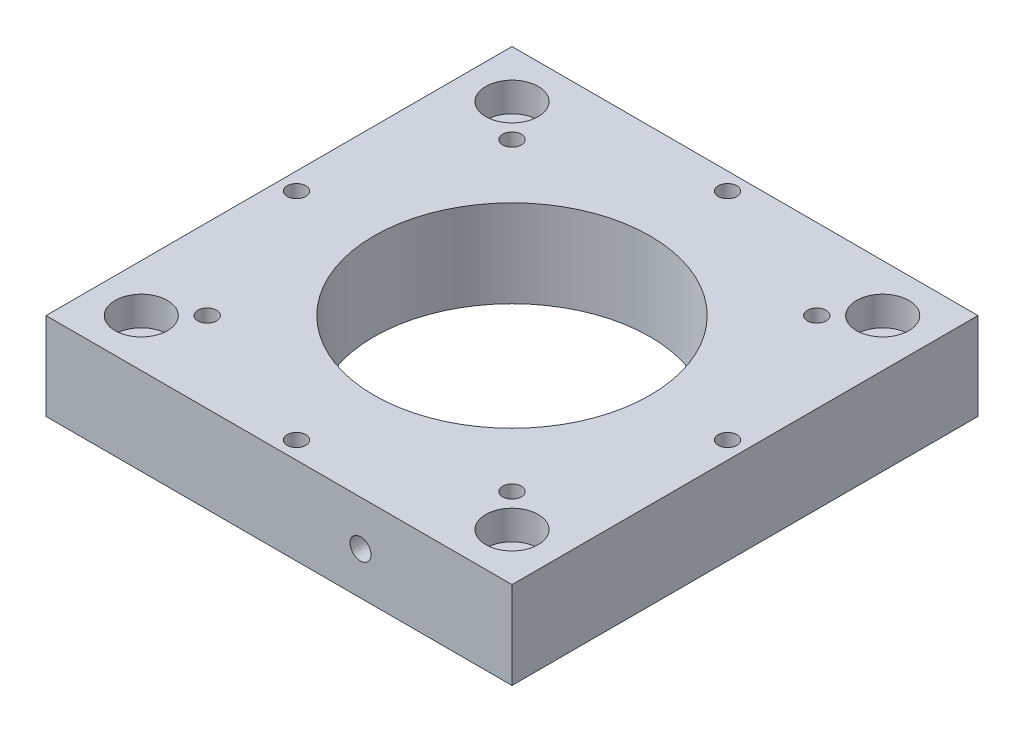
from build123d import *

# Parameters (mm, degrees)
SKETCH_22_W         = 80
SKETCH_22_H         = 80
SKETCH_22_R         = 1.6
SKETCH_22_R_2       = 23.7
SKETCH_22_R_3       = 2.6
EXTRUDE_1_DEPTH     = 15
SKETCH_24_R         = 2.9
CUT_EXTRUDE_2_DEPTH = 5
SKETCH_26_R         = 4.5
CUT_EXTRUDE_4_DEPTH = 5
SKETCH_31_R         = 1.8
CUT_EXTRUDE_6_DEPTH = 12
SKETCH_36_R         = 1.8
CUT_EXTRUDE_9_DEPTH = 12


with BuildPart() as part:
    # 草图22 → 凸台-拉伸1 (new body)
    with BuildSketch(Plane(origin=(0, 0, 0), x_dir=(1, 0, 0), z_dir=(0, 1, 0))):
        Rectangle(SKETCH_22_W, SKETCH_22_H)
        with Locations((0, 37)):
            Circle(SKETCH_22_R, mode=Mode.SUBTRACT)
        with Locations((26.162950904, 26.162950904)):
            Circle(SKETCH_22_R, mode=Mode.SUBTRACT)
        with Locations((37, 0)):
            Circle(SKETCH_22_R, mode=Mode.SUBTRACT)
        with Locations((26.162950904, -26.162950904)):
            Circle(SKETCH_22_R, mode=Mode.SUBTRACT)
        with Locations((0, -37)):
            Circle(SKETCH_22_R, mode=Mode.SUBTRACT)
        with Locations((-26.162950904, -26.162950904)):
            Circle(SKETCH_22_R, mode=Mode.SUBTRACT)
        with Locations((-37, 0)):
            Circle(SKETCH_22_R, mode=Mode.SUBTRACT)
        with Locations((-26.162950904, 26.162950904)):
            Circle(SKETCH_22_R, mode=Mode.SUBTRACT)
        Circle(SKETCH_22_R_2, mode=Mode.SUBTRACT)
        with Locations((-31.819805153, 31.819805153)):
            Circle(SKETCH_22_R_3, mode=Mode.SUBTRACT)
        with Locations((-31.819805153, -31.819805153)):
            Circle(SKETCH_22_R_3, mode=Mode.SUBTRACT)
        with Locations((31.819805153, -31.819805153)):
            Circle(SKETCH_22_R_3, mode=Mode.SUBTRACT)
        with Locations((31.819805153, 31.819805153)):
            Circle(SKETCH_22_R_3, mode=Mode.SUBTRACT)
    extrude(amount=EXTRUDE_1_DEPTH)

    # 草图24 → 切除-拉伸2 (cut)
    with BuildSketch(Plane.XZ):
        with Locations((0, 37)):
            Circle(SKETCH_24_R)
        with Locations((26.162950904, 26.162950904)):
            Circle(SKETCH_24_R)
        with Locations((37, 0)):
            Circle(SKETCH_24_R)
        with Locations((26.162950904, -26.162950904)):
            Circle(SKETCH_24_R)
        with Locations((0, -37)):
            Circle(SKETCH_24_R)
        with Locations((-26.162950904, -26.162950904)):
            Circle(SKETCH_24_R)
        with Locations((-37, 0)):
            Circle(SKETCH_24_R)
        with Locations((-26.162950904, 26.162950904)):
            Circle(SKETCH_24_R)
    extrude(amount=-CUT_EXTRUDE_2_DEPTH, mode=Mode.SUBTRACT)

    # 草图26 → 切除-拉伸4 (cut)
    with BuildSketch(Plane(origin=(0, 15, 0), x_dir=(1, 0, 0), z_dir=(0, 1, 0))):
        with Locations((-31.819805153, 31.819805153)):
            Circle(SKETCH_26_R)
        with Locations((31.819805153, 31.819805153)):
            Circle(SKETCH_26_R)
        with Locations((31.819805153, -31.819805153)):
            Circle(SKETCH_26_R)
        with Locations((-31.819805153, -31.819805153)):
            Circle(SKETCH_26_R)
    extrude(amount=-CUT_EXTRUDE_4_DEPTH, mode=Mode.SUBTRACT)

    # 草图31 → 切除-拉伸6 (cut)
    with BuildSketch(Plane.XY.offset(40)):
        with Locations((13.998307963, 7.310553575)):
            Circle(SKETCH_31_R)
    extrude(amount=-CUT_EXTRUDE_6_DEPTH, mode=Mode.SUBTRACT)

    # 草图36 → 切除-拉伸9 (cut)
    with BuildSketch(Plane(origin=(0, 0, -40), x_dir=(-1, 0, 0), z_dir=(0, 0, -1))):
        with Locations((-16.504769552, 7.351157317)):
            Circle(SKETCH_36_R)
    extrude(amount=-CUT_EXTRUDE_9_DEPTH, mode=Mode.SUBTRACT)


solid = part.part
